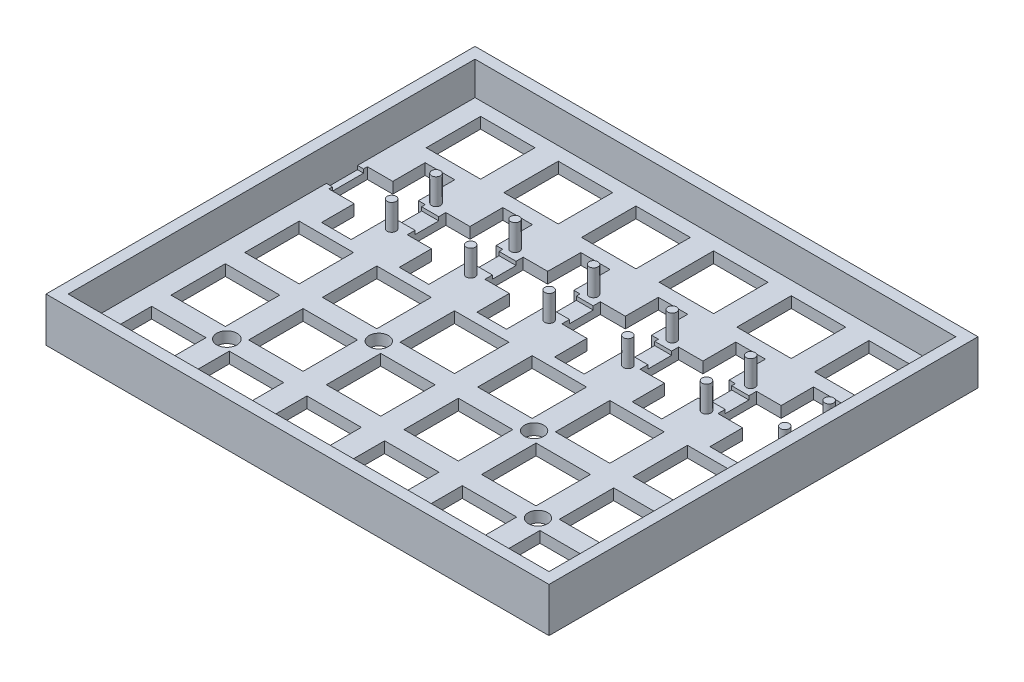
from build123d import *

# Parameters (mm, degrees)
SKETCH2_W                        = 136
SKETCH2_H                        = 136
BOSS_EXTRUDE1_DEPTH              = 25
SKETCH3_W                        = 118
SKETCH3_H                        = 118
CUT_EXTRUDE1_DEPTH               = 22
CUT_EXTRUDE3_DEPTH               = 22
CUT_EXTRUDE4_DEPTH               = 22
SKETCH7_W                        = 29.69848481
SKETCH7_H                        = 30.00387357
BOSS_EXTRUDE2_DEPTH              = 25
BOSS_EXTRUDE3_DEPTH              = 3
CUT_EXTRUDE5_DEPTH               = 23
CUT_EXTRUDE6_DEPTH               = 22
CUT_EXTRUDE7_DEPTH               = 32
BOSS_EXTRUDE6_DEPTH              = 6.36
BOSS_EXTRUDE7_DEPTH              = 6.36
CUT_EXTRUDE9_DEPTH               = 6.36
CUT_EXTRUDE10_DEPTH              = 56.36
BOSS_EXTRUDE8_DEPTH              = 3
BOSS_EXTRUDE9_START              = -20
BOSS_EXTRUDE9_DEPTH              = 2
SKETCH23_W                       = 29.69848481
SKETCH23_H                       = 2
BOSS_EXTRUDE10_DEPTH             = 1.5
SKETCH24_W                       = 10.361394494
SKETCH24_H                       = 0.734081985
CUT_EXTRUDE11_DEPTH              = 31.5
BOSS_EXTRUDE11_DEPTH             = 4
BOSS_EXTRUDE12_DEPTH             = 44
CUT_EXTRUDE12_DEPTH              = 50
BOSS_EXTRUDE13_DEPTH             = 3
BOSS_EXTRUDE14_DEPTH             = 22
SKETCH33_W                       = 130
SKETCH33_H                       = 130
CUT_EXTRUDE13_DEPTH              = 22
CUT_EXTRUDE15_DEPTH              = 12
CUT_EXTRUDE16_DEPTH              = 32
BOSS_EXTRUDE15_DEPTH             = 22
BOSS_EXTRUDE15_DEPTH_BACK        = 3
BOSS_EXTRUDE17_DEPTH             = 15
SKETCH38_W                       = 136
SKETCH38_H                       = 116
SKETCH38_W_2                     = 130
SKETCH38_H_2                     = 110
CUT_EXTRUDE17_DEPTH              = 13
SKETCH39_W                       = 136
SKETCH39_H                       = 116
SKETCH39_W_2                     = 130
SKETCH39_H_2                     = 110
BOSS_EXTRUDE18_DEPTH             = 13
SKETCH40_W                       = 136
SKETCH40_H                       = 116
SKETCH40_W_2                     = 130
SKETCH40_H_2                     = 110
BOSS_EXTRUDE19_DEPTH             = 1
SKETCH41_W                       = 136
SKETCH41_H                       = 116
SKETCH41_W_2                     = 130
SKETCH41_H_2                     = 110
CUT_EXTRUDE18_DEPTH              = 14
SKETCH42_W                       = 14.71
SKETCH42_H                       = 14.71
CUT_EXTRUDE19_DEPTH              = 10
SKETCH44_R                       = 1.2
BOSS_EXTRUDE21_DEPTH             = 7
SKETCH46_W                       = 6.4
SKETCH46_H                       = 2
CUT_EXTRUDE20_DEPTH              = 157
SKETCH47_W                       = 8.402493679
SKETCH47_H                       = 2
CUT_EXTRUDE21_DEPTH              = 157
BOSS_EXTRUDE22_START             = -3
SKETCH48_W                       = 8.402493679
SKETCH48_H                       = 2
BOSS_EXTRUDE22_DEPTH             = 3
BOSS_EXTRUDE23_START             = -3
SKETCH49_W                       = 8.402493679
SKETCH49_H                       = 2
BOSS_EXTRUDE23_DEPTH             = 3
SKETCH50_W                       = 1.866474956
SKETCH50_H                       = 8.402493679
SKETCH50_W_2                     = 1.792981344
SKETCH50_W_3                     = 1.451738129
SKETCH50_W_4                     = 1.682796132
SKETCH50_W_5                     = 1.864628185
SKETCH50_W_6                     = 1.688024478
SKETCH50_W_7                     = 1.398847141
SKETCH50_W_8                     = 1.783653604
SKETCH50_W_9                     = 1.478936861
SKETCH50_W_10                    = 1.847396209
SKETCH50_W_11                    = 1.561310522
CUT_EXTRUDE22_DEPTH              = 10
SKETCH51_W                       = 4.002348603
SKETCH51_H                       = 10.416797859
SKETCH51_H_2                     = 10.41679786
CUT_EXTRUDE23_DEPTH              = 10
SKETCH52_R                       = 2.741156087
SKETCH52_R_2                     = 2.617535223
CUT_EXTRUDE25_DEPTH              = 10
SKETCH53_W                       = 0.562332249
SKETCH53_H                       = 8.402493679
CUT_EXTRUDE26_DEPTH              = 10
CUT_EXTRUDE27_DEPTH              = 15
CUT_EXTRUDE28_START              = -3
SKETCH55_W                       = 2.867838718
SKETCH55_H                       = 8.402493679
CUT_EXTRUDE28_DEPTH              = 2
CUT_EXTRUDE29_START              = -3
SKETCH56_W                       = 2.867838718
SKETCH56_H                       = 1.037641561
SKETCH56_H_2                     = 0.97666262
CUT_EXTRUDE29_DEPTH              = 3
SKETCH57_W                       = 6.527236797
SKETCH57_H                       = 10.416797859
SKETCH57_W_2                     = 6.666758975
SKETCH57_H_2                     = 10.41679786
CUT_EXTRUDE30_DEPTH              = 3
SKETCH58_W                       = 1.432831283
SKETCH58_H                       = 8.402493679
SKETCH58_W_2                     = 1.451156421
BOSS_EXTRUDE24_DEPTH             = 2
SKETCH59_W                       = 1.307514883
SKETCH59_H                       = 8.402493679
SKETCH59_W_2                     = 1.381297298
SKETCH59_W_3                     = 1.284979154
BOSS_EXTRUDE25_DEPTH             = 2
BOSS_EXTRUDE27_REACH             = 84.705
SKETCH61_W                       = 6.61702143
SKETCH61_H                       = 3
BOSS_EXTRUDE27_DIRECTION_2_DEPTH = 1
BOSS_EXTRUDE28_REACH             = 84.558
SKETCH62_W                       = 6.763689556
SKETCH62_H                       = 3
BOSS_EXTRUDE28_DIRECTION_2_DEPTH = 1
SKETCH63_W                       = 8.574077198
SKETCH63_H                       = 3
BOSS_EXTRUDE29_DEPTH             = 1
SKETCH64_W                       = 9.225669385
SKETCH64_H                       = 3
BOSS_EXTRUDE30_DEPTH             = 1
SKETCH65_W                       = 1.332505971
SKETCH65_H                       = 8.402493679
CUT_EXTRUDE31_DEPTH              = 11
SKETCH66_W                       = 4.65
SKETCH66_H                       = 8.402493679
BOSS_EXTRUDE32_DEPTH             = 2
SKETCH67_W                       = 4.65
SKETCH67_H                       = 1
SKETCH67_W_2                     = 4.650444893
SKETCH67_W_3                     = 4.572970309
SKETCH67_W_4                     = 4.548396617
SKETCH67_W_5                     = 4.599708951
SKETCH67_W_6                     = 4.625366994
BOSS_EXTRUDE33_DEPTH             = 1
SKETCH68_W                       = 136
SKETCH68_H                       = 116
BOSS_EXTRUDE34_DEPTH             = 0.25
SKETCH69_W                       = 14.71
SKETCH69_H                       = 14.71
SKETCH69_W_2                     = 1.421192795
SKETCH69_H_2                     = 8.402493679
CUT_EXTRUDE32_DEPTH              = 0.25
SKETCH70_R                       = 2.617535223
SKETCH70_R_2                     = 2.741156087
CUT_EXTRUDE33_DEPTH              = 0.25


with BuildPart() as part:
    # Sketch2 → Boss-Extrude1 (new body)
    with BuildSketch(Plane(origin=(0, 0, 0), x_dir=(1, 0, 0), z_dir=(0, 1, 0))):
        with Locations((9.299145299, -9.88034188)):
            Rectangle(SKETCH2_W, SKETCH2_H)
    extrude(amount=BOSS_EXTRUDE1_DEPTH)

    # Sketch3 → Cut-Extrude1 (cut)
    with BuildSketch(Plane(origin=(0, 25, 0), x_dir=(1, 0, 0), z_dir=(0, 1, 0))):
        with Locations((9.299145299, -9.88034188)):
            Rectangle(SKETCH3_W, SKETCH3_H)
    extrude(amount=-CUT_EXTRUDE1_DEPTH, mode=Mode.SUBTRACT)

    # Sketch4 → Cut-Extrude3 (cut)
    with BuildSketch(Plane(origin=(0, 25, 0), x_dir=(1, 0, 0), z_dir=(0, 1, 0))):
        Polygon((77.299145299, -77.88034188), (47.299145299, -77.88034188), (47.299145299, -68.88034188), (56.299145299, -68.88034188), (68.299145299, -56.88034188), (68.299145299, -47.88034188), (77.299145299, -47.88034188), align=None)
    extrude(amount=-CUT_EXTRUDE3_DEPTH, mode=Mode.SUBTRACT)

    # Sketch5 → Cut-Extrude4 (cut)
    with BuildSketch(Plane(origin=(0, 3, 0), x_dir=(1, 0, 0), z_dir=(0, 1, 0))):
        Polygon((68.299145299, -47.88034188), (47.299145299, -68.88034188), (47.299145299, -77.88034188), (77.299145299, -77.88034188), (77.299145299, -47.88034188), align=None)
    extrude(amount=-CUT_EXTRUDE4_DEPTH, mode=Mode.SUBTRACT)

    # Sketch7 → Boss-Extrude2 (add)
    with BuildSketch(Plane(origin=(58.08974359, 0, 58.08974359), x_dir=(0.707106781, 0, -0.707106781), z_dir=(0.707106781, 0, 0.707106781))):
        with Locations((-0.410968044, -12.001936785)):
            Rectangle(SKETCH7_W, SKETCH7_H)
    extrude(amount=BOSS_EXTRUDE2_DEPTH)

    # Sketch8 → Boss-Extrude3 (add)
    with BuildSketch(Plane(origin=(0, 3, 0), x_dir=(1, 0, 0), z_dir=(0, 1, 0))):
        Polygon((47.299145299, -77.88034188), (77.299145299, -47.88034188), (68.299145299, -47.88034188), (47.299145299, -68.88034188), align=None)
    extrude(amount=-BOSS_EXTRUDE3_DEPTH)

    # Sketch9 → Cut-Extrude5 (cut)
    with BuildSketch(Plane(origin=(0, 3, 0), x_dir=(1, 0, 0), z_dir=(0, 1, 0))):
        Polygon((47.299145299, -77.88034188), (38.299145299, -68.88034188), (47.299145299, -68.88034188), align=None)
    extrude(amount=CUT_EXTRUDE5_DEPTH, mode=Mode.SUBTRACT)

    # Sketch10 → Cut-Extrude6 (cut)
    with BuildSketch(Plane(origin=(0, 25, 0), x_dir=(1, 0, 0), z_dir=(0, 1, 0))):
        Polygon((77.299145299, -47.88034188), (68.299145299, -38.88034188), (68.299145299, -47.88034188), align=None)
    extrude(amount=-CUT_EXTRUDE6_DEPTH, mode=Mode.SUBTRACT)

    # Sketch11 → Cut-Extrude7 (cut)
    with BuildSketch(Plane(origin=(-10.790598291, 0, 10.790598291), x_dir=(0.707106781, 0, 0.707106781), z_dir=(-0.707106781, 0, 0.707106781))):
        Polygon((88.51526425, 0), (107.151303219, -18.636038969), (107.151303219, -27.00387357), (82.151303219, -27.00387357), (82.151303219, 0), align=None)
        Polygon((88.51526425, 3), (107.151303219, -15.636038969), (107.151303219, 3), align=None)
    extrude(amount=-CUT_EXTRUDE7_DEPTH, mode=Mode.SUBTRACT)

    # Sketch16 → Boss-Extrude6 (add)
    with BuildSketch(Plane(origin=(-10.790598291, 0, 10.790598291), x_dir=(0.707106781, 0, 0.707106781), z_dir=(-0.707106781, 0, 0.707106781))):
        Polygon((88.51526425, 0), (88.51526425, 3), (107.151303219, -15.636038969), (107.151303219, -18.636038969), align=None)
    extrude(amount=BOSS_EXTRUDE6_DEPTH)

    # Sketch17 → Boss-Extrude7 (add)
    with BuildSketch(Plane(origin=(10.209401709, 0, -10.209401709), x_dir=(-0.707106781, 0, -0.707106781), z_dir=(0.707106781, 0, -0.707106781))):
        Polygon((-88.51526425, 0), (-88.51526425, 3), (-107.151303219, -15.636038969), (-107.151303219, -18.636038969), align=None)
    extrude(amount=BOSS_EXTRUDE7_DEPTH)

    # Sketch18 → Cut-Extrude9 (cut)
    with BuildSketch(Plane(origin=(32.355531967, 45.757632125, 32.355531967), x_dir=(0.866025404, -0.40824829, -0.288675135), z_dir=(0.5, 0.707106781, 0.5))):
        Polygon((51.893180344, -37.364371534), (67.109442444, -58.883415765), (61.91652419, -62.555363477), align=None)
        Polygon((32.474894629, -83.373739388), (37.667812884, -79.701791676), (17.258632528, -61.854695157), align=None)
    extrude(amount=-CUT_EXTRUDE9_DEPTH, mode=Mode.SUBTRACT)

    # Sketch19 → Cut-Extrude10 (cut)
    with BuildSketch(Plane(origin=(-15.287797419, 0, 15.287797419), x_dir=(0.707106781, 0, 0.707106781), z_dir=(-0.707106781, 0, 0.707106781))):
        Polygon((107.151303219, -18.636038969), (107.151303219, -15.636038969), (105.651303219, -17.136038969), align=None)
    extrude(amount=-CUT_EXTRUDE10_DEPTH, mode=Mode.SUBTRACT)

    # Sketch20 → Boss-Extrude8 (add)
    with BuildSketch(Plane.XZ):
        Polygon((-58.700854701, 77.88034188), (47.299145299, 77.88034188), (77.299145299, 47.88034188), (77.299145299, -58.11965812), (-58.700854701, -58.11965812), align=None)
    extrude(amount=-BOSS_EXTRUDE8_DEPTH)



with BuildPart() as body_2:
    # Sketch22 → Boss-Extrude9 (new body)
    with BuildSketch(Plane(origin=(0, 3, 0), x_dir=(1, 0, 0), z_dir=(0, 1, 0)).offset(BOSS_EXTRUDE9_START)):
        Polygon((64.976814829, -86.55801141), (70.906234285, -91.928484844), (91.906234285, -70.928484844), (85.976814829, -65.55801141), align=None)
    extrude(amount=BOSS_EXTRUDE9_DEPTH)


with BuildPart() as part_1:
    add(part.part)

    add(body_2.part)  # Boss-Extrude10 merges body 2
    # Sketch23 → Boss-Extrude10 (add)
    with BuildSketch(Plane(origin=(75.767413119, 0, 75.767413119), x_dir=(-0.707106781, 0, 0.707106781), z_dir=(-0.707106781, 0, -0.707106781))):
        with Locations((0.410968044, -16)):
            Rectangle(SKETCH23_W, SKETCH23_H)
    extrude(amount=BOSS_EXTRUDE10_DEPTH)

    # Sketch24 → Cut-Extrude11 (cut)
    with BuildSketch(Plane(origin=(-13.785543706, 0, 15.220310104), x_dir=(0.741177432, 0, 0.671309179), z_dir=(-0.671309179, 0, 0.741177432))):
        with Locations((109.085839112, -17.367040993)):
            Rectangle(SKETCH24_W, SKETCH24_H)
    extrude(amount=-CUT_EXTRUDE11_DEPTH, mode=Mode.SUBTRACT)

    # Sketch28 → Boss-Extrude11 (add)
    with BuildSketch(Plane(origin=(32.355531967, 45.757632125, 32.355531967), x_dir=(0.866025404, -0.40824829, -0.288675135), z_dir=(0.5, 0.707106781, 0.5))):
        Polygon((17.25539836, -61.856982059), (8.148098637, -53.895706291), (47.339944519, -25.921031992), (51.893180344, -37.364371534), align=None)
    extrude(amount=-BOSS_EXTRUDE11_DEPTH)

    # Sketch29 → Boss-Extrude12 (add)
    with BuildSketch(Plane(origin=(14.709401709, 0, -14.709401709), x_dir=(0.707106781, 0, 0.707106781), z_dir=(-0.707106781, 0, 0.707106781))):
        Polygon((80.058656938, 11.456607312), (75.787342189, 11.456607312), (75.787342189, 3), (82.858410001, 3), align=None)
    extrude(amount=BOSS_EXTRUDE12_DEPTH)

    # Sketch30 → Cut-Extrude12 (cut)
    with BuildSketch(Plane(origin=(0, 25, 0), x_dir=(1, 0, 0), z_dir=(0, 1, 0))):
        Polygon((38.299145299, -68.88034188), (68.299145299, -38.88034188), (77.299145299, -47.88034188), (91.906234285, -70.928484844), (70.906234285, -91.928484844), (47.299145299, -77.88034188), align=None)
    extrude(amount=-CUT_EXTRUDE12_DEPTH, mode=Mode.SUBTRACT)

    # Sketch31 → Boss-Extrude13 (add)
    with BuildSketch(Plane(origin=(0, 3, 0), x_dir=(1, 0, 0), z_dir=(0, 1, 0))):
        Polygon((68.299145299, -38.88034188), (77.299145299, -47.88034188), (77.299145299, -77.88034188), (47.299145299, -77.88034188), (38.299145299, -68.88034188), align=None)
    extrude(amount=-BOSS_EXTRUDE13_DEPTH)

    # Sketch32 → Boss-Extrude14 (add)
    with BuildSketch(Plane(origin=(0, 3, 0), x_dir=(1, 0, 0), z_dir=(0, 1, 0))):
        Polygon((77.299145299, -77.88034188), (77.299145299, -47.88034188), (68.299145299, -38.88034188), (68.299145299, -68.88034188), (38.299145299, -68.88034188), (47.299145299, -77.88034188), align=None)
    extrude(amount=BOSS_EXTRUDE14_DEPTH)

    # Sketch33 → Cut-Extrude13 (cut)
    with BuildSketch(Plane(origin=(0, 25, 0), x_dir=(1, 0, 0), z_dir=(0, 1, 0))):
        with Locations((9.299145299, -9.88034188)):
            Rectangle(SKETCH33_W, SKETCH33_H)
    extrude(amount=-CUT_EXTRUDE13_DEPTH, mode=Mode.SUBTRACT)

    # Sketch34 → Cut-Extrude15 (cut)
    with BuildSketch(Plane(origin=(0, 3, 0), x_dir=(1, 0, 0), z_dir=(0, 1, 0))):
        Polygon((-43.200854701, -14.866207324), (-39.200854701, -14.866207324), (-39.200854701, 13.133792676), (-47.200854701, 13.133792676), (-47.200854701, -14.866207324), align=None)
        Polygon((-22.200854701, -14.865867711), (-18.200854701, -14.865867711), (-18.200854701, 13.133792676), (-26.200854701, 13.133792676), (-26.200854701, -14.865867711), align=None)
        Polygon((-1.200854701, -14.865528099), (2.799145299, -14.865528099), (2.799145299, 13.133792676), (-5.200854701, 13.133792676), (-5.200854701, -14.865528099), align=None)
        Polygon((19.799145299, -14.865188486), (23.799145299, -14.865188486), (23.799145299, 13.133792676), (15.799145299, 13.133792676), (15.799145299, -14.865188486), align=None)
        Polygon((40.799145299, -14.864848873), (44.799145299, -14.864848873), (44.799145299, 13.133792676), (36.799145299, 13.133792676), (36.799145299, -14.864848873), align=None)
        Polygon((61.799145299, -14.86450926), (65.799145299, -14.86450926), (65.799145299, 13.133792676), (57.799145299, 13.133792676), (57.799145299, -14.86450926), align=None)
    extrude(amount=-CUT_EXTRUDE15_DEPTH, mode=Mode.SUBTRACT)

    # Sketch35 → Cut-Extrude16 (cut)
    with BuildSketch(Plane(origin=(0, 25, 0), x_dir=(1, 0, 0), z_dir=(0, 1, 0))):
        Polygon((-55.700854701, 35.11965812), (77.299145299, 35.11965812), (77.299145299, 58.11965812), (-58.700854701, 58.11965812), (-58.700854701, 35.11965812), align=None)
    extrude(amount=-CUT_EXTRUDE16_DEPTH, mode=Mode.SUBTRACT)

    # Sketch36 → Boss-Extrude15 (add, two sides)
    with BuildSketch(Plane(origin=(0, 3, 0), x_dir=(1, 0, 0), z_dir=(0, 1, 0))) as boss_extrude15_sk:
        Polygon((-58.700854701, 35.11965812), (-55.700854701, 35.11965812), (77.299145299, 35.11965812), (77.299145299, 38.11965812), (-58.700854701, 38.11965812), align=None)
    extrude(amount=BOSS_EXTRUDE15_DEPTH)
    extrude(boss_extrude15_sk.sketch, amount=-BOSS_EXTRUDE15_DEPTH_BACK)

    # Sketch37 → Boss-Extrude17 (add)
    with BuildSketch(Plane(origin=(0, 0, 0), x_dir=(-1, 0, 0), z_dir=(0, -1, 0))):
        with BuildLine():
            Line((55.700854701, 35.11965812), (46.700854701, 35.11965812))
            ThreePointArc((46.700854701, 35.11965812), (49.33689367, 28.755697089), (55.700854701, 26.11965812))
            Line((55.700854701, 26.11965812), (55.700854701, 35.11965812))
        make_face()
        with BuildLine():
            Line((55.700854701, -65.88034188), (55.700854701, -74.88034188))
            Line((55.700854701, -74.88034188), (46.700854701, -74.88034188))
            ThreePointArc((46.700854701, -74.88034188), (49.33689367, -68.51638085), (55.700854701, -65.88034188))
        make_face()
    extrude(amount=BOSS_EXTRUDE17_DEPTH)

    # Sketch38 → Cut-Extrude17 (cut)
    with BuildSketch(Plane(origin=(0, 25, 0), x_dir=(1, 0, 0), z_dir=(0, 1, 0))):
        with Locations((9.299145299, -19.88034188)):
            Rectangle(SKETCH38_W, SKETCH38_H)
        with Locations((9.299145299, -19.88034188)):
            Rectangle(SKETCH38_W_2, SKETCH38_H_2, mode=Mode.SUBTRACT)
    extrude(amount=-CUT_EXTRUDE17_DEPTH, mode=Mode.SUBTRACT)

    # Sketch39 → Boss-Extrude18 (add)
    with BuildSketch(Plane(origin=(0, 12, 0), x_dir=(1, 0, 0), z_dir=(0, 1, 0))):
        with Locations((9.299145299, -19.88034188)):
            Rectangle(SKETCH39_W, SKETCH39_H)
        with Locations((9.299145299, -19.88034188)):
            Rectangle(SKETCH39_W_2, SKETCH39_H_2, mode=Mode.SUBTRACT)
    extrude(amount=BOSS_EXTRUDE18_DEPTH)

    # Sketch40 → Boss-Extrude19 (add)
    with BuildSketch(Plane(origin=(0, 25, 0), x_dir=(1, 0, 0), z_dir=(0, 1, 0))):
        with Locations((9.299145299, -19.88034188)):
            Rectangle(SKETCH40_W, SKETCH40_H)
        with Locations((9.299145299, -19.88034188)):
            Rectangle(SKETCH40_W_2, SKETCH40_H_2, mode=Mode.SUBTRACT)
    extrude(amount=BOSS_EXTRUDE19_DEPTH)

    # Sketch41 → Cut-Extrude18 (cut)
    with BuildSketch(Plane(origin=(0, 26, 0), x_dir=(1, 0, 0), z_dir=(0, 1, 0))):
        with Locations((9.299145299, -19.88034188)):
            Rectangle(SKETCH41_W, SKETCH41_H)
        with Locations((9.299145299, -19.88034188)):
            Rectangle(SKETCH41_W_2, SKETCH41_H_2, mode=Mode.SUBTRACT)
    extrude(amount=-CUT_EXTRUDE18_DEPTH, mode=Mode.SUBTRACT)

    # Sketch42 → Cut-Extrude19 (cut)
    with BuildSketch(Plane(origin=(0, 3, 0), x_dir=(1, 0, 0), z_dir=(0, 1, 0))):
        with Locations((-22.200854701, -24.935271435)):
            Rectangle(SKETCH42_W, SKETCH42_H)
        with Locations((-1.200854701, -24.935271435)):
            Rectangle(SKETCH42_W, SKETCH42_H)
        with Locations((19.799145299, -24.935271435)):
            Rectangle(SKETCH42_W, SKETCH42_H)
        with Locations((40.799145299, -24.935271435)):
            Rectangle(SKETCH42_W, SKETCH42_H)
        with Locations((61.799145299, -24.935271435)):
            Rectangle(SKETCH42_W, SKETCH42_H)
        with Locations((61.799145299, -44.88034188)):
            Rectangle(SKETCH42_W, SKETCH42_H)
        with Locations((40.799145299, -44.88034188)):
            Rectangle(SKETCH42_W, SKETCH42_H)
        with Locations((40.799145299, -64.825412326)):
            Rectangle(SKETCH42_W, SKETCH42_H)
        with Locations((61.799145299, -64.825412326)):
            Rectangle(SKETCH42_W, SKETCH42_H)
        with Locations((19.799145299, -64.825412326)):
            Rectangle(SKETCH42_W, SKETCH42_H)
        with Locations((19.799145299, -44.88034188)):
            Rectangle(SKETCH42_W, SKETCH42_H)
        with Locations((-1.200854701, -44.88034188)):
            Rectangle(SKETCH42_W, SKETCH42_H)
        with Locations((-1.200854701, -64.825412326)):
            Rectangle(SKETCH42_W, SKETCH42_H)
        with Locations((-22.200854701, -44.88034188)):
            Rectangle(SKETCH42_W, SKETCH42_H)
        with Locations((-22.200854701, -64.825412326)):
            Rectangle(SKETCH42_W, SKETCH42_H)
        with Locations((-43.200854701, -44.88034188)):
            Rectangle(SKETCH42_W, SKETCH42_H)
        with Locations((-43.200854701, -64.825412326)):
            Rectangle(SKETCH42_W, SKETCH42_H)
        with Locations((-43.200854701, -24.935271435)):
            Rectangle(SKETCH42_W, SKETCH42_H)
        Polygon((-35.845854701, 31.481725398), (-35.845854701, 16.771725398), (-43.200854701, 16.771725398), (-50.555854701, 16.771725398), (-50.555854701, 31.481725398), (-43.200854701, 31.481725398), align=None)
        with Locations((-22.200854701, 24.126725398)):
            Rectangle(SKETCH42_W, SKETCH42_H)
        with Locations((-1.200854701, 24.126725398)):
            Rectangle(SKETCH42_W, SKETCH42_H)
        with Locations((19.799145299, 24.126725398)):
            Rectangle(SKETCH42_W, SKETCH42_H)
        with Locations((40.799145299, 24.126725398)):
            Rectangle(SKETCH42_W, SKETCH42_H)
        with Locations((61.799145299, 24.126725398)):
            Rectangle(SKETCH42_W, SKETCH42_H)
    extrude(amount=-CUT_EXTRUDE19_DEPTH, mode=Mode.SUBTRACT)

    # Sketch44 → Boss-Extrude21 (add)
    with BuildSketch(Plane(origin=(0, 3, 0), x_dir=(1, 0, 0), z_dir=(0, 1, 0))):
        with Locations((70.07545428, -6.903447403)):
            Circle(SKETCH44_R)
        with Locations((70.07545428, 5.096357364)):
            Circle(SKETCH44_R)
        with Locations((48.867775453, -6.859352213)):
            Circle(SKETCH44_R)
        with Locations((48.867775453, 5.096357364)):
            Circle(SKETCH44_R)
        with Locations((27.596212232, 5.158255103)):
            Circle(SKETCH44_R)
        with Locations((27.596212232, -6.841549664)):
            Circle(SKETCH44_R)
        with Locations((6.357700624, -6.889849019)):
            Circle(SKETCH44_R)
        with Locations((6.357700624, 5.109955748)):
            Circle(SKETCH44_R)
        with Locations((-14.854009647, 5.097693574)):
            Circle(SKETCH44_R)
        with Locations((-14.854009647, -6.902111194)):
            Circle(SKETCH44_R)
        with Locations((-36.266999412, -6.860516757)):
            Circle(SKETCH44_R)
        with Locations((-36.266999412, 5.13928801)):
            Circle(SKETCH44_R)
    extrude(amount=BOSS_EXTRUDE21_DEPTH)

    # Sketch46 → Cut-Extrude20 (cut)
    with BuildSketch(Plane.ZY.offset(58.700854701)):
        with Locations((0.862747186, 3)):
            Rectangle(SKETCH46_W, SKETCH46_H)
    extrude(amount=-CUT_EXTRUDE20_DEPTH, mode=Mode.SUBTRACT)

    # Sketch47 → Cut-Extrude21 (cut)
    with BuildSketch(Plane.ZY.offset(58.700854701)):
        with Locations((0.861500346, 3)):
            Rectangle(SKETCH47_W, SKETCH47_H)
    extrude(amount=-CUT_EXTRUDE21_DEPTH, mode=Mode.SUBTRACT)

    # Sketch48 → Boss-Extrude22 (add)
    with BuildSketch(Plane.ZY.offset(58.700854701).offset(BOSS_EXTRUDE22_START)):
        with Locations((0.861500346, 3)):
            Rectangle(SKETCH48_W, SKETCH48_H)
    extrude(amount=BOSS_EXTRUDE22_DEPTH)

    # Sketch49 → Boss-Extrude23 (add)
    with BuildSketch(Plane(origin=(77.299145299, 0, 0), x_dir=(0, 0, -1), z_dir=(1, 0, 0)).offset(BOSS_EXTRUDE23_START)):
        with Locations((-0.861500346, 3)):
            Rectangle(SKETCH49_W, SKETCH49_H)
    extrude(amount=BOSS_EXTRUDE23_DEPTH)

    # Sketch50 → Cut-Extrude22 (cut)
    with BuildSketch(Plane(origin=(0, 2, 0), x_dir=(1, 0, 0), z_dir=(0, 1, 0))):
        with Locations((67.294715026, -0.861500346)):
            Rectangle(SKETCH50_W, SKETCH50_H)
        with Locations((72.070148656, -0.861500346)):
            Rectangle(SKETCH50_W_2, SKETCH50_H)
        with Locations((50.573276234, -0.861500346)):
            Rectangle(SKETCH50_W_3, SKETCH50_H)
        with Locations((45.640543365, -0.861500346)):
            Rectangle(SKETCH50_W_4, SKETCH50_H)
        with Locations((24.731459392, -0.861500346)):
            Rectangle(SKETCH50_W_5, SKETCH50_H)
        Polygon((28.855446495, 3.339746493), (28.855446495, -5.062747186), (30.28275823, -5.062747186), (30.299145299, 3.339746493), align=None)
        with Locations((3.643157538, -0.861500346)):
            Rectangle(SKETCH50_W_6, SKETCH50_H)
        with Locations((8.427475082, -0.861500346)):
            Rectangle(SKETCH50_W_7, SKETCH50_H)
        with Locations((-17.309027899, -0.861500346)):
            Rectangle(SKETCH50_W_8, SKETCH50_H)
        with Locations((-12.529180137, -0.861500346)):
            Rectangle(SKETCH50_W_9, SKETCH50_H)
        with Locations((-38.277156597, -0.861500346)):
            Rectangle(SKETCH50_W_10, SKETCH50_H)
        with Locations((-33.38026752, -0.861500346)):
            Rectangle(SKETCH50_W_11, SKETCH50_H)
    extrude(amount=-CUT_EXTRUDE22_DEPTH, mode=Mode.SUBTRACT)

    # Sketch51 → Cut-Extrude23 (cut)
    with BuildSketch(Plane.XZ):
        with Locations((-30.726917197, 0.955109855)):
            Rectangle(SKETCH51_W, SKETCH51_H)
        with Locations((-52.06986772, 0.831010876)):
            Rectangle(SKETCH51_W, SKETCH51_H_2)
        with Locations((-108.697764872, -101.924495701)):
            Rectangle(SKETCH51_W, SKETCH51_H_2)
        with Locations((-9.816317845, 0.883825136)):
            Rectangle(SKETCH51_W, SKETCH51_H_2)
        with Locations((-88.330048801, -101.924495701)):
            Rectangle(SKETCH51_W, SKETCH51_H_2)
        with Locations((-71.40238764, -101.924495701)):
            Rectangle(SKETCH51_W, SKETCH51_H_2)
        with Locations((11.036740696, 0.916421388)):
            Rectangle(SKETCH51_W, SKETCH51_H_2)
        with Locations((32.237918095, 0.977502106)):
            Rectangle(SKETCH51_W, SKETCH51_H_2)
        with Locations((53.133560626, 0.813515484)):
            Rectangle(SKETCH51_W, SKETCH51_H_2)
    extrude(amount=-CUT_EXTRUDE23_DEPTH, mode=Mode.SUBTRACT)

    # Sketch52 → Cut-Extrude25 (cut)
    with BuildSketch(Plane(origin=(0, 0, 0), x_dir=(-1, 0, 0), z_dir=(0, -1, 0))):
        with Locations((32.700854701, -54.976497967)):
            Circle(SKETCH52_R)
        with Locations((-51.299145299, -54.852877103)):
            Circle(SKETCH52_R_2)
        with Locations((11.700854701, -34.907806658)):
            Circle(SKETCH52_R_2)
        with Locations((-30.299145299, -34.907806658)):
            Circle(SKETCH52_R_2)
    extrude(amount=-CUT_EXTRUDE25_DEPTH, mode=Mode.SUBTRACT)

    # Sketch53 → Cut-Extrude26 (cut)
    with BuildSketch(Plane.XZ):
        with Locations((66.080311424, 0.861500346)):
            Rectangle(SKETCH53_W, SKETCH53_H)
    extrude(amount=-CUT_EXTRUDE26_DEPTH, mode=Mode.SUBTRACT)

    # Sketch54 → Cut-Extrude27 (cut)
    with BuildSketch(Plane.XZ.offset(15)):
        with BuildLine():
            Line((-46.700854701, 74.88034188), (-55.700854701, 74.88034188))
            Line((-55.700854701, 74.88034188), (-55.700854701, 65.88034188))
            ThreePointArc((-55.700854701, 65.88034188), (-49.33689367, 68.51638085), (-46.700854701, 74.88034188))
        make_face()
        with BuildLine():
            Line((-55.700854701, -26.11965812), (-55.700854701, -35.11965812))
            Line((-55.700854701, -35.11965812), (-46.700854701, -35.11965812))
            ThreePointArc((-46.700854701, -35.11965812), (-49.33689367, -28.755697089), (-55.700854701, -26.11965812))
        make_face()
    extrude(amount=-CUT_EXTRUDE27_DEPTH, mode=Mode.SUBTRACT)

    # Sketch55 → Cut-Extrude28 (cut)
    with BuildSketch(Plane(origin=(0, 3, 0), x_dir=(1, 0, 0), z_dir=(0, 1, 0)).offset(CUT_EXTRUDE28_START)):
        with Locations((-48.63477406, -0.861500346)):
            Rectangle(SKETCH55_W, SKETCH55_H)
    extrude(amount=CUT_EXTRUDE28_DEPTH, mode=Mode.SUBTRACT)

    # Sketch56 → Cut-Extrude29 (cut)
    with BuildSketch(Plane(origin=(0, 3, 0), x_dir=(1, 0, 0), z_dir=(0, 1, 0)).offset(CUT_EXTRUDE29_START)):
        with Locations((-48.63477406, 3.858567274)):
            Rectangle(SKETCH56_W, SKETCH56_H)
        with Locations((-48.63477406, -5.551078496)):
            Rectangle(SKETCH56_W, SKETCH56_H_2)
    extrude(amount=CUT_EXTRUDE29_DEPTH, mode=Mode.SUBTRACT)

    # Sketch57 → Cut-Extrude30 (cut)
    with BuildSketch(Plane(origin=(0, 3, 0), x_dir=(1, 0, 0), z_dir=(0, 1, 0))):
        with Locations((-29.4644731, -0.955109855)):
            Rectangle(SKETCH57_W, SKETCH57_H)
        Polygon((-11.817492146, 4.324573794), (-11.817492146, -6.092224066), (-5.200854701, -6.092224066), (-5.200854701, 4.253289074), align=None)
        Polygon((9.035566394, -6.124820318), (15.799145299, -6.124820318), (15.799145299, 4.253289074), (9.035566394, 4.291977542), align=None)
        Polygon((30.236743793, -6.185901036), (30.236743793, 4.230896824), (36.799145299, 4.230896824), (36.799145299, -6.124820318), align=None)
        with Locations((54.465765812, -0.813515484)):
            Rectangle(SKETCH57_W_2, SKETCH57_H_2)
    extrude(amount=-CUT_EXTRUDE30_DEPTH, mode=Mode.SUBTRACT)

    # Sketch58 → Boss-Extrude24 (add)
    with BuildSketch(Plane(origin=(0, 2, 0), x_dir=(1, 0, 0), z_dir=(0, 1, 0))):
        with Locations((-33.44450714, -0.861500346)):
            Rectangle(SKETCH58_W, SKETCH58_H)
        with Locations((-12.543070357, -0.861500346)):
            Rectangle(SKETCH58_W_2, SKETCH58_H)
    extrude(amount=-BOSS_EXTRUDE24_DEPTH)

    # Sketch59 → Boss-Extrude25 (add)
    with BuildSketch(Plane(origin=(0, 2, 0), x_dir=(1, 0, 0), z_dir=(0, 1, 0))):
        with Locations((8.381808953, -0.861500346)):
            Rectangle(SKETCH59_W, SKETCH59_H)
        with Locations((29.546095144, -0.861500346)):
            Rectangle(SKETCH59_W_2, SKETCH59_H)
        with Locations((50.489896747, -0.861500346)):
            Rectangle(SKETCH59_W_3, SKETCH59_H)
    extrude(amount=-BOSS_EXTRUDE25_DEPTH)

    # Boss-Extrude27: up to this face of the body (flat: up to its plane)
    boss_extrude27_end = Plane(part_1.part.faces().sort_by_distance((-29.464473099, 1.5, -4.253289074))[0])
    # Sketch61 → Boss-Extrude27 (add, up to the picked face)
    with BuildSketch(Plane(origin=(0.045214143, 0, -4.196770253), x_dir=(0.99994197, 0, 0.010772932), z_dir=(-0.010772932, 0, 0.99994197)), mode=Mode.PRIVATE) as boss_extrude27_sk1:
        with Locations((-8.554884004, 1.5)):
            Rectangle(SKETCH61_W, SKETCH61_H)
    boss_extrude27_tool1 = split(extrude(boss_extrude27_sk1.sketch, amount=BOSS_EXTRUDE27_REACH, mode=Mode.PRIVATE), bisect_by=boss_extrude27_end, keep=Keep.BOTH, mode=Mode.PRIVATE)
    add(boss_extrude27_tool1.solids().sort_by_distance((-8.509173, 1.5, -4.288931))[0])

    # Sketch61 → Boss-Extrude27 direction 2 (add)
    with BuildSketch(Plane(origin=(0.045214143, 0, -4.196770253), x_dir=(0.99994197, 0, 0.010772932), z_dir=(-0.010772932, 0, 0.99994197))):
        with Locations((-8.554884004, 1.5)):
            Rectangle(SKETCH61_W, SKETCH61_H)
    extrude(amount=-BOSS_EXTRUDE27_DIRECTION_2_DEPTH)

    # Boss-Extrude28: up to this face of the body (flat: up to its plane)
    boss_extrude28_end = Plane(part_1.part.faces().sort_by_distance((-29.464473099, 1.5, -4.253289074))[0])
    # Sketch62 → Boss-Extrude28 (add, up to the picked face)
    with BuildSketch(Plane(origin=(0.024845445, 0, -4.343519926), x_dir=(0.999983641, 0, 0.005720024), z_dir=(-0.005720024, 0, 0.999983641)), mode=Mode.PRIVATE) as boss_extrude28_sk1:
        with Locations((12.39271314, 1.5)):
            Rectangle(SKETCH62_W, SKETCH62_H)
    boss_extrude28_tool1 = split(extrude(boss_extrude28_sk1.sketch, amount=BOSS_EXTRUDE28_REACH, mode=Mode.PRIVATE), bisect_by=boss_extrude28_end, keep=Keep.BOTH, mode=Mode.PRIVATE)
    add(boss_extrude28_tool1.solids().sort_by_distance((12.417356, 1.5, -4.272633))[0])

    # Sketch62 → Boss-Extrude28 direction 2 (add)
    with BuildSketch(Plane(origin=(0.024845445, 0, -4.343519926), x_dir=(0.999983641, 0, 0.005720024), z_dir=(-0.005720024, 0, 0.999983641))):
        with Locations((12.39271314, 1.5)):
            Rectangle(SKETCH62_W, SKETCH62_H)
    extrude(amount=-BOSS_EXTRUDE28_DIRECTION_2_DEPTH)

    # Sketch63 → Boss-Extrude29 (add)
    with BuildSketch(Plane(origin=(15.774299854, 0, 0.090230851), x_dir=(0.005720024, 0, -0.999983641), z_dir=(0.999983641, 0, 0.005720024))):
        with Locations((9.630629584, 1.5)):
            Rectangle(SKETCH63_W, SKETCH63_H)
    extrude(amount=-BOSS_EXTRUDE29_DEPTH)

    # Sketch64 → Boss-Extrude30 (add)
    with BuildSketch(Plane(origin=(-5.246068844, 0, -0.056518821), x_dir=(0.010772932, 0, -0.99994197), z_dir=(0.99994197, 0, 0.010772932))):
        with Locations((9.809848498, 1.5)):
            Rectangle(SKETCH64_W, SKETCH64_H)
    extrude(amount=-BOSS_EXTRUDE30_DEPTH)

    # Sketch65 → Cut-Extrude31 (cut)
    with BuildSketch(Plane(origin=(0, 2, 0), x_dir=(1, 0, 0), z_dir=(0, 1, 0))):
        with Locations((73.632892314, -0.861500346)):
            Rectangle(SKETCH65_W, SKETCH65_H)
    extrude(amount=-CUT_EXTRUDE31_DEPTH, mode=Mode.SUBTRACT)

    # Sketch66 → Boss-Extrude32 (add)
    with BuildSketch(Plane(origin=(0, 2, 0), x_dir=(1, 0, 0), z_dir=(0, 1, 0))):
        with Locations((70.552952504, -0.861500346)):
            Rectangle(SKETCH66_W, SKETCH66_H)
    extrude(amount=-BOSS_EXTRUDE32_DEPTH)

    # Sketch67 → Boss-Extrude33 (add)
    with BuildSketch(Plane(origin=(0, 2, 0), x_dir=(1, 0, 0), z_dir=(0, 1, 0))):
        with Locations((70.552952504, -4.562747186)):
            Rectangle(SKETCH67_W, SKETCH67_H)
        with Locations((48.807163878, -4.562747186)):
            Rectangle(SKETCH67_W_2, SKETCH67_H)
        with Locations((70.552952504, 2.839746493)):
            Rectangle(SKETCH67_W, SKETCH67_H)
        with Locations((48.807163878, 2.839746493)):
            Rectangle(SKETCH67_W_2, SKETCH67_H)
        with Locations((27.950258639, 2.839746493)):
            Rectangle(SKETCH67_W_3, SKETCH67_H)
        with Locations((27.950258639, -4.562747186)):
            Rectangle(SKETCH67_W_3, SKETCH67_H)
        with Locations((6.761368086, -4.562747186)):
            Rectangle(SKETCH67_W_4, SKETCH67_H)
        with Locations((6.761368086, 2.839746493)):
            Rectangle(SKETCH67_W_4, SKETCH67_H)
        with Locations((-14.117346622, -4.562747186)):
            Rectangle(SKETCH67_W_5, SKETCH67_H)
        with Locations((-35.040774995, -4.562747186)):
            Rectangle(SKETCH67_W_6, SKETCH67_H)
        with Locations((-14.117346622, 2.839746493)):
            Rectangle(SKETCH67_W_5, SKETCH67_H)
        with Locations((-35.040774995, 2.839746493)):
            Rectangle(SKETCH67_W_6, SKETCH67_H)
    extrude(amount=BOSS_EXTRUDE33_DEPTH)

    # Sketch68 → Boss-Extrude34 (add)
    with BuildSketch(Plane.XZ):
        with Locations((9.299145299, 19.88034188)):
            Rectangle(SKETCH68_W, SKETCH68_H)
    extrude(amount=-BOSS_EXTRUDE34_DEPTH)

    # Sketch69 → Cut-Extrude32 (cut)
    with BuildSketch(Plane(origin=(0, 0.25, 0), x_dir=(1, 0, 0), z_dir=(0, 1, 0))):
        with Locations((-43.200854701, -24.935271435)):
            Rectangle(SKETCH69_W, SKETCH69_H)
        with Locations((-43.200854701, -44.88034188)):
            Rectangle(SKETCH69_W, SKETCH69_H)
        with Locations((-43.200854701, -64.825412326)):
            Rectangle(SKETCH69_W, SKETCH69_H)
        with Locations((-22.200854701, -64.825412326)):
            Rectangle(SKETCH69_W, SKETCH69_H)
        with Locations((-22.200854701, -44.88034188)):
            Rectangle(SKETCH69_W, SKETCH69_H)
        with Locations((-22.200854701, -24.935271435)):
            Rectangle(SKETCH69_W, SKETCH69_H)
        with Locations((-1.200854701, -24.935271435)):
            Rectangle(SKETCH69_W, SKETCH69_H)
        with Locations((-1.200854701, -44.88034188)):
            Rectangle(SKETCH69_W, SKETCH69_H)
        with Locations((-1.200854701, -64.825412326)):
            Rectangle(SKETCH69_W, SKETCH69_H)
        with Locations((19.799145299, -64.825412326)):
            Rectangle(SKETCH69_W, SKETCH69_H)
        with Locations((40.799145299, -24.935271435)):
            Rectangle(SKETCH69_W, SKETCH69_H)
        with Locations((19.799145299, -24.935271435)):
            Rectangle(SKETCH69_W, SKETCH69_H)
        with Locations((19.799145299, -44.88034188)):
            Rectangle(SKETCH69_W, SKETCH69_H)
        with Locations((40.799145299, -44.88034188)):
            Rectangle(SKETCH69_W, SKETCH69_H)
        with Locations((40.799145299, -64.825412326)):
            Rectangle(SKETCH69_W, SKETCH69_H)
        with Locations((61.799145299, -64.825412326)):
            Rectangle(SKETCH69_W, SKETCH69_H)
        with Locations((61.799145299, -44.88034188)):
            Rectangle(SKETCH69_W, SKETCH69_H)
        with Locations((61.799145299, -24.935271435)):
            Rectangle(SKETCH69_W, SKETCH69_H)
        with Locations((73.588548902, -0.861500346)):
            Rectangle(SKETCH69_W_2, SKETCH69_H_2)
        Polygon((-39.200854701, -5.062747186), (-37.353458492, -5.062747186), (-37.353458492, 3.339746493), (-39.200854701, 3.339746493), (-39.200854701, 13.133792676), (-47.200854701, 13.133792676), (-47.200854701, 4.377388054), (-54.071042022, 4.377388054), (-54.071042022, -6.039409806), (-47.200854701, -6.039409806), (-47.200854701, -14.866207324), (-39.200854701, -14.866207324), align=None)
        Polygon((-16.417201097, 3.339746493), (-18.200854701, 3.339746493), (-18.200854701, 13.133792676), (-26.200854701, 13.133792676), (-26.200854701, 4.253289074), (-32.728091498, 4.253289074), (-32.728091498, -6.163508785), (-26.200854701, -6.163508785), (-26.200854701, -14.865867711), (-18.200854701, -14.865867711), (-18.200854701, -5.062747186), (-16.417201097, -5.062747186), align=None)
        Polygon((2.799145299, -5.062747186), (4.487169777, -5.062747186), (4.487169777, 3.339746493), (2.799145299, 3.339746493), (2.799145299, 13.133792676), (-5.10518009, 13.133792676), (-5.200854701, 4.253289074), (-11.817492146, 4.253289074), (-11.817492146, -6.092224066), (-5.200854701, -6.092224066), (-5.200854701, -14.865528099), (2.799145299, -14.865528099), align=None)
        Polygon((23.799145299, -5.062747186), (25.663773484, -5.062747186), (25.663773484, 3.339746493), (23.799145299, 3.339746493), (23.799145299, 13.133792676), (15.849942825, 13.133792676), (15.799145299, 4.253289074), (9.035566394, 4.253289074), (9.035566394, -6.124820318), (15.799145299, -6.124820318), (15.799145299, -14.865188486), (23.799145299, -14.865188486), align=None)
        Polygon((46.481941431, 3.339746493), (44.799145299, 3.339746493), (44.799145299, 13.133792676), (36.799145299, 13.133792676), (36.799145299, 4.230896824), (30.236743793, 4.230896824), (30.236743793, -6.185901036), (34.239092396, -6.185901036), (34.239092396, -6.148648465), (36.799145299, -6.124820318), (36.799145299, -14.864848873), (44.799145299, -14.864848873), (44.799145299, -5.062747186), (46.481941431, -5.062747186), align=None)
        Polygon((68.227952504, 3.339746493), (65.799145299, 3.339746493), (65.799145299, 13.133792676), (57.799145299, 13.133792676), (57.799145299, 4.394883446), (51.132386324, 4.394883446), (51.132386324, -6.021914414), (57.799145299, -6.021914414), (57.799145299, -14.86450926), (65.799145299, -14.86450926), (65.799145299, -5.062747186), (68.227952504, -5.062747186), align=None)
        with Locations((61.799145299, 24.126725398)):
            Rectangle(SKETCH69_W, SKETCH69_H)
        with Locations((40.799145299, 24.126725398)):
            Rectangle(SKETCH69_W, SKETCH69_H)
        with Locations((19.799145299, 24.126725398)):
            Rectangle(SKETCH69_W, SKETCH69_H)
        with Locations((-1.200854701, 24.126725398)):
            Rectangle(SKETCH69_W, SKETCH69_H)
        with Locations((-22.200854701, 24.126725398)):
            Rectangle(SKETCH69_W, SKETCH69_H)
        with Locations((-43.200854701, 24.126725398)):
            Rectangle(SKETCH69_W, SKETCH69_H)
    extrude(amount=-CUT_EXTRUDE32_DEPTH, mode=Mode.SUBTRACT)

    # Sketch70 → Cut-Extrude33 (cut)
    with BuildSketch(Plane(origin=(0, 0.25, 0), x_dir=(1, 0, 0), z_dir=(0, 1, 0))):
        with Locations((51.299145299, -54.852877103)):
            Circle(SKETCH70_R)
        with Locations((30.299145299, -34.907806658)):
            Circle(SKETCH70_R)
        with Locations((-11.700854701, -34.907806658)):
            Circle(SKETCH70_R)
        with Locations((-32.700854701, -54.976497967)):
            Circle(SKETCH70_R_2)
    extrude(amount=-CUT_EXTRUDE33_DEPTH, mode=Mode.SUBTRACT)


solid = part_1.part
